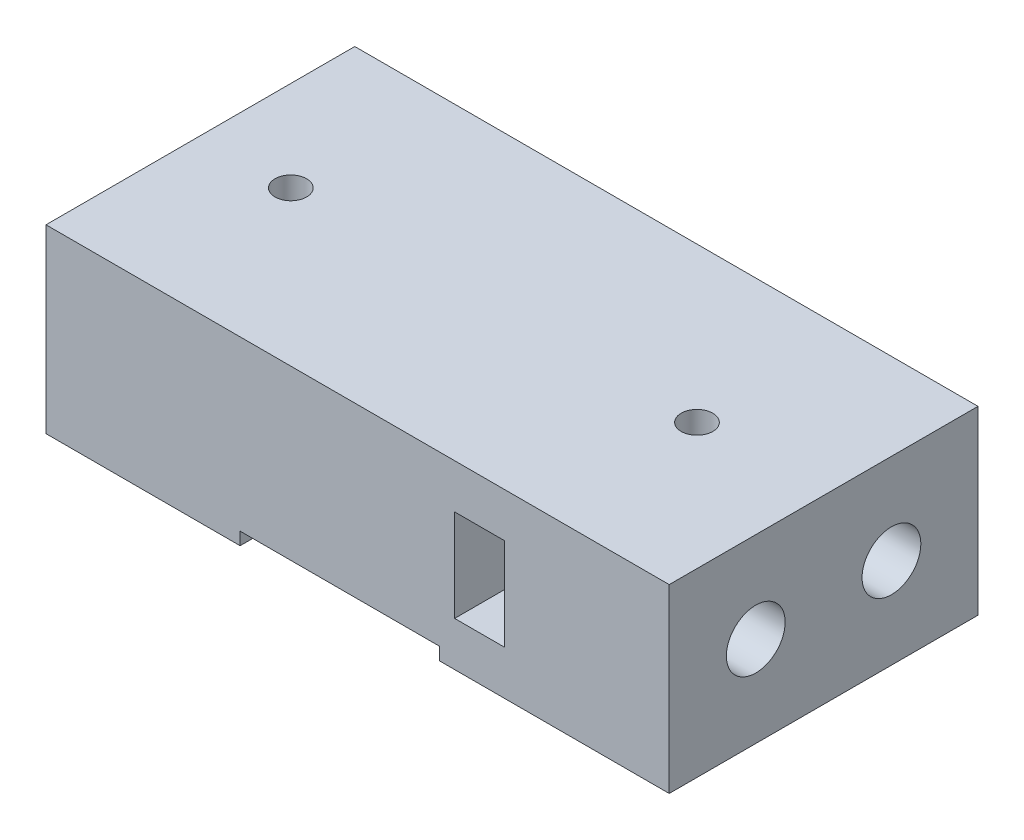
from build123d import *

# Parameters (mm, degrees)
SKETCH1_W           = 68.896006058
SKETCH1_H           = 34.135361424
BOSS_EXTRUDE1_DEPTH = 20
CUT_EXTRUDE1_REACH  = 36.135
SKETCH2_W           = 22.032289941
SKETCH2_H           = 1.4
SKETCH7_R           = 3.25
CUT_EXTRUDE4_DEPTH  = 30
CUT_EXTRUDE5_REACH  = 22
SKETCH8_R           = 1.75
SKETCH9_W           = 5.5
SKETCH9_H           = 10.2
CUT_EXTRUDE6_DEPTH  = 35.135361425
SKETCH10_W          = 22.032289941
SKETCH10_H          = 2.8
CUT_EXTRUDE7_DEPTH  = 1.5
CUT_EXTRUDE7_TAPER  = 20
LPATTERN1_COUNT     = 7
LPATTERN1_PITCH     = 5


with BuildPart() as part:
    # Sketch1 → Boss-Extrude1 (new body)
    with BuildSketch(Plane(origin=(0, 0, 0), x_dir=(1, 0, 0), z_dir=(0, 1, 0))):
        Rectangle(SKETCH1_W, SKETCH1_H)
    extrude(amount=BOSS_EXTRUDE1_DEPTH)

    # Sketch2 → Cut-Extrude1 (cut, up to next)
    with BuildSketch(Plane(origin=(0, 0, -17.067680712), x_dir=(-1, 0, 0), z_dir=(0, 0, -1)), mode=Mode.PRIVATE) as cut_extrude1_sk1:
        with Locations((1.973306179, 0.7)):
            Rectangle(SKETCH2_W, SKETCH2_H)
    cut_extrude1_tool1 = extrude(cut_extrude1_sk1.sketch, amount=-CUT_EXTRUDE1_REACH, mode=Mode.PRIVATE) & part.part
    add(cut_extrude1_tool1.solids().sort_by_distance((-1.973306, 0.7, -17.067681))[0], mode=Mode.SUBTRACT)

    # Sketch7 → Cut-Extrude4 (cut)
    with BuildSketch(Plane(origin=(34.448003029, 0, 0), x_dir=(0, 0, -1), z_dir=(1, 0, 0))):
        with Locations((-7.5, 10)):
            Circle(SKETCH7_R)
        with Locations((7.5, 10)):
            Circle(SKETCH7_R)
    extrude(amount=-CUT_EXTRUDE4_DEPTH, mode=Mode.SUBTRACT)

    # Sketch8 → Cut-Extrude5 (cut, up to next)
    with BuildSketch(Plane.XZ, mode=Mode.PRIVATE) as cut_extrude5_sk1:
        with Locations((-24.448003029, 0)):
            Circle(SKETCH8_R)
    cut_extrude5_tool1 = extrude(cut_extrude5_sk1.sketch, amount=-CUT_EXTRUDE5_REACH, mode=Mode.PRIVATE) & part.part
    add(cut_extrude5_tool1.solids().sort_by_distance((-24.448003, 0, 0))[0], mode=Mode.SUBTRACT)
    # Sketch8 → Cut-Extrude5 (cut, up to next)
    with BuildSketch(Plane.XZ, mode=Mode.PRIVATE) as cut_extrude5_sk2:
        with Locations((20.448003029, 0)):
            Circle(SKETCH8_R)
    cut_extrude5_tool2 = extrude(cut_extrude5_sk2.sketch, amount=-CUT_EXTRUDE5_REACH, mode=Mode.PRIVATE) & part.part
    add(cut_extrude5_tool2.solids().sort_by_distance((20.448003, 0, 0))[0], mode=Mode.SUBTRACT)

    # Sketch9 → Cut-Extrude6 (cut, through all)
    with BuildSketch(Plane(origin=(0, 0, -17.067680712), x_dir=(-1, 0, 0), z_dir=(0, 0, -1))):
        with Locations((-13.475884112, 10)):
            Rectangle(SKETCH9_W, SKETCH9_H)
    extrude(amount=-CUT_EXTRUDE6_DEPTH, mode=Mode.SUBTRACT)

    # Sketch10 → Cut-Extrude7 (cut)
    with BuildSketch(Plane.XZ.offset(-1.4)):
        with Locations((-1.973306179, 13.755042689)):
            Rectangle(SKETCH10_W, SKETCH10_H)
    cut_extrude7 = extrude(amount=-CUT_EXTRUDE7_DEPTH, taper=CUT_EXTRUDE7_TAPER, mode=Mode.SUBTRACT)

    # LPattern1: Cut-Extrude7 ×7
    with Locations(*[(0, 0, -i * LPATTERN1_PITCH) for i in range(1, LPATTERN1_COUNT)]):
        add(cut_extrude7, mode=Mode.SUBTRACT)


solid = part.part
